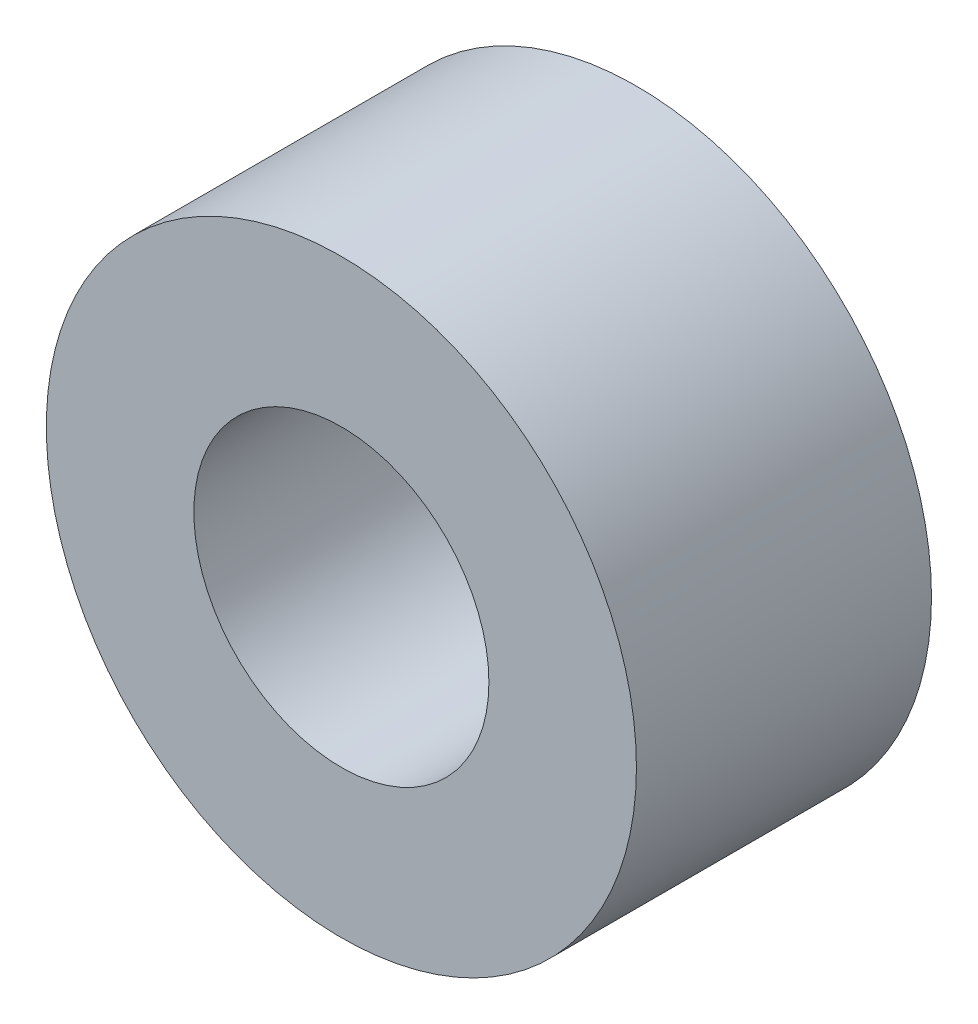
from build123d import *

# Parameters (mm, degrees)
SKETCH1_R           = 5
SKETCH1_R_2         = 2.5
BOSS_EXTRUDE1_DEPTH = 5


with BuildPart() as part:
    # Sketch1 → Boss-Extrude1 (new body)
    with BuildSketch(Plane.XY):
        with Locations((-17.295778932, 9.229064833)):
            Circle(SKETCH1_R)
        with Locations((-17.295778932, 9.229064833)):
            Circle(SKETCH1_R_2, mode=Mode.SUBTRACT)
    extrude(amount=BOSS_EXTRUDE1_DEPTH)


solid = part.part
